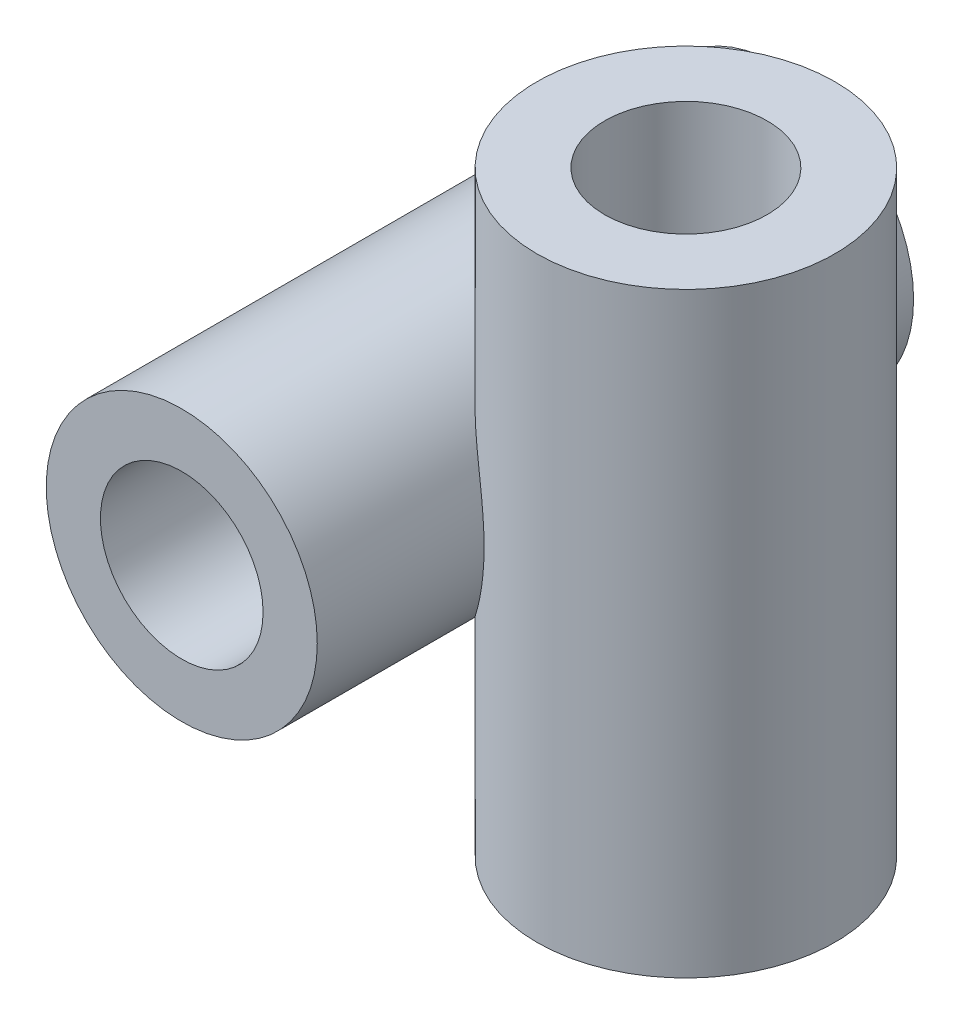
from build123d import *

# Parameters (mm, degrees)
SKETCH1_R           = 25
BOSS_EXTRUDE1_DEPTH = 110
SKETCH2_R           = 27.5
BOSS_EXTRUDE2_DEPTH = 55
SKETCH3_R           = 15
CUT_EXTRUDE1_DEPTH  = 110
SKETCH4_R           = 15
CUT_EXTRUDE3_DEPTH  = 110


with BuildPart() as part:
    # Sketch1 → Boss-Extrude1 (new body)
    with BuildSketch(Plane.XY):
        Circle(SKETCH1_R)
    extrude(amount=BOSS_EXTRUDE1_DEPTH)

    # Sketch2 → Boss-Extrude2 (add, symmetric)
    with BuildSketch(Plane(origin=(0, 0, 0), x_dir=(1, 0, 0), z_dir=(0, 1, 0))):
        with Locations((38, -55)):
            Circle(SKETCH2_R)
    extrude(amount=BOSS_EXTRUDE2_DEPTH, both=True)

    # Sketch3 → Cut-Extrude1 (cut)
    with BuildSketch(Plane.XY.offset(110)):
        Circle(SKETCH3_R)
    extrude(amount=-CUT_EXTRUDE1_DEPTH, mode=Mode.SUBTRACT)

    # Sketch4 → Cut-Extrude3 (cut)
    with BuildSketch(Plane(origin=(0, 55, 0), x_dir=(1, 0, 0), z_dir=(0, 1, 0))):
        with Locations((38, -55)):
            Circle(SKETCH4_R)
    extrude(amount=-CUT_EXTRUDE3_DEPTH, mode=Mode.SUBTRACT)


solid = part.part
